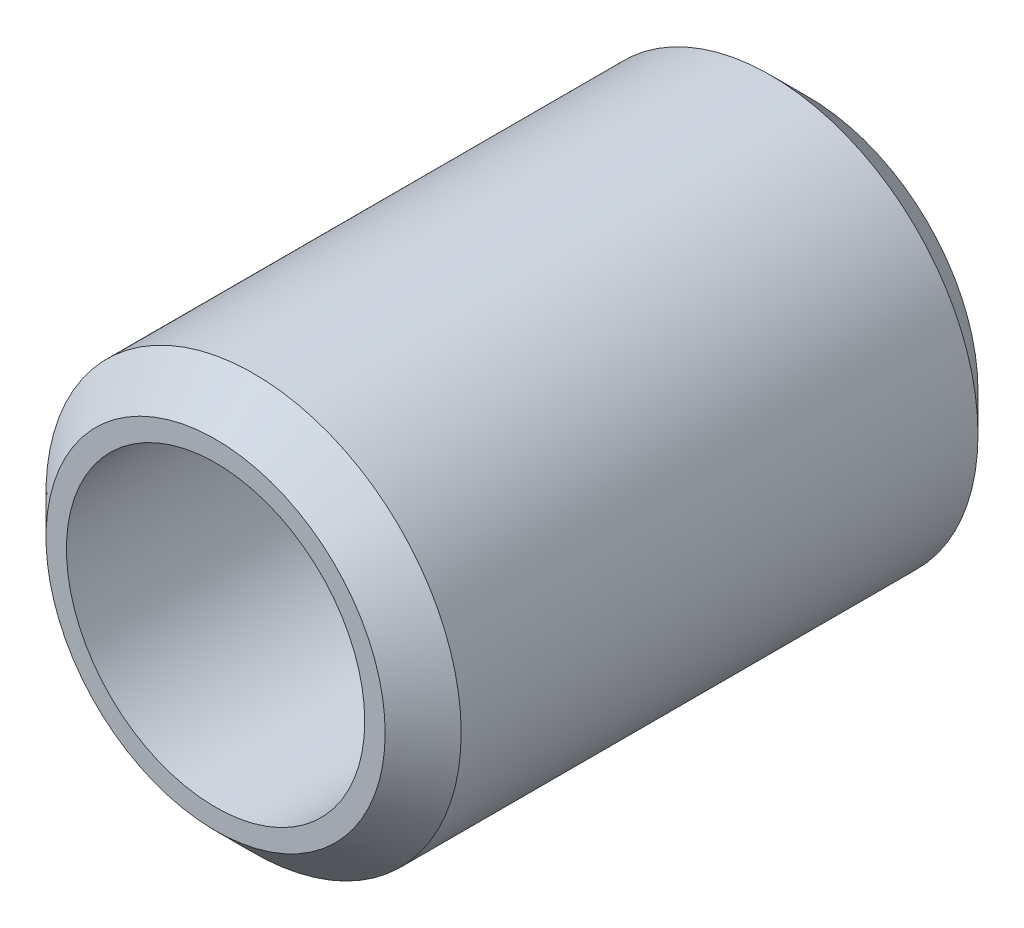
from build123d import *


with BuildPart() as part:
    # Sketch1 → Revolve1 (revolve)
    with BuildSketch(Plane(origin=(0, 0, 0), x_dir=(0, 0, -1), z_dir=(1, 0, 0))):
        Polygon((-3.9624, 2.26695), (-3.9624, 1.9939), (3.9624, 1.9939), (3.9624, 2.26695), (3.4544, 2.77495), (-3.4544, 2.77495), align=None)
    revolve(axis=Axis((0, 0, -3.9624), (0, 0, 1)))


solid = part.part
